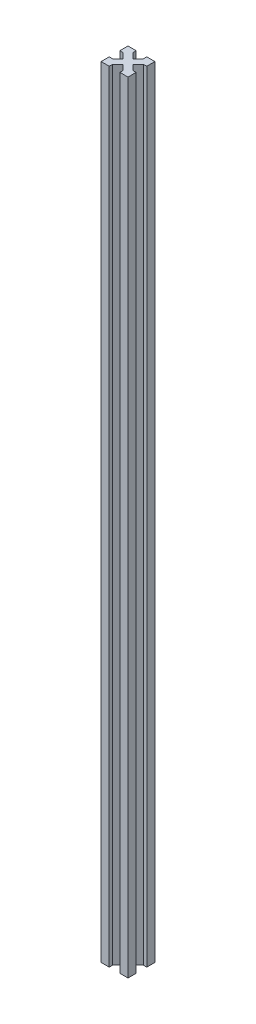
from build123d import *

# Parameters (mm, degrees)
BOSS_EXTRU_1_DEPTH = 580


with BuildPart() as part:
    # Esquisse1 → Boss.-Extru.1 (new body)
    with BuildSketch(Plane(origin=(0, 0, 0), x_dir=(1, 0, 0), z_dir=(0, 1, 0))):
        Polygon((-3.535533906, 0), (-6.035533906, 2.5), (-6.035533906, 0), align=None)
        Polygon((0, 3.535533906), (-2.5, 6.035533906), (-2.5, 2.5), (-6.035533906, 2.5), (-3.535533906, 0), (0, 0), align=None)
        Polygon((0, 6.035533906), (-2.5, 6.035533906), (0, 3.535533906), align=None)
        Polygon((-2.5, 2.5), (-2.5, 6.035533906), (-6.464466094, 10), (-10, 6.464466094), (-6.035533906, 2.5), align=None)
        Polygon((-13.964466094, 0), (-13.964466094, 2.5), (-16.464466094, 0), align=None)
        Polygon((-17.5, 2.5), (-17.5, 6.035533906), (-20, 3.535533906), (-20, 0), (-16.464466094, 0), (-13.964466094, 2.5), align=None)
        Polygon((-20, 3.535533906), (-17.5, 6.035533906), (-20, 6.035533906), align=None)
        Polygon((-10, 6.464466094), (-13.535533906, 10), (-17.5, 6.035533906), (-17.5, 2.5), (-13.964466094, 2.5), align=None)
        Polygon((-6.464466094, 10), (-10, 13.535533906), (-13.535533906, 10), (-10, 6.464466094), align=None)
        Polygon((-2.5, 13.964466094), (-2.5, 17.5), (-6.035533906, 17.5), (-10, 13.535533906), (-6.464466094, 10), align=None)
        Polygon((-6.035533906, 17.5), (-2.5, 17.5), (-2.5, 13.964466094), (0, 16.464466094), (0, 20), (-3.535533906, 20), align=None)
        Polygon((0, 16.464466094), (-2.5, 13.964466094), (0, 13.964466094), align=None)
        Polygon((-6.035533906, 20), (-6.035533906, 17.5), (-3.535533906, 20), align=None)
        Polygon((-16.464466094, 20), (-13.964466094, 17.5), (-13.964466094, 20), align=None)
        Polygon((-17.5, 17.5), (-13.964466094, 17.5), (-16.464466094, 20), (-20, 20), (-20, 16.464466094), (-17.5, 13.964466094), align=None)
        Polygon((-20, 13.964466094), (-17.5, 13.964466094), (-20, 16.464466094), align=None)
        Polygon((-10, 13.535533906), (-13.964466094, 17.5), (-17.5, 17.5), (-17.5, 13.964466094), (-13.535533906, 10), align=None)
    extrude(amount=BOSS_EXTRU_1_DEPTH)


solid = part.part
